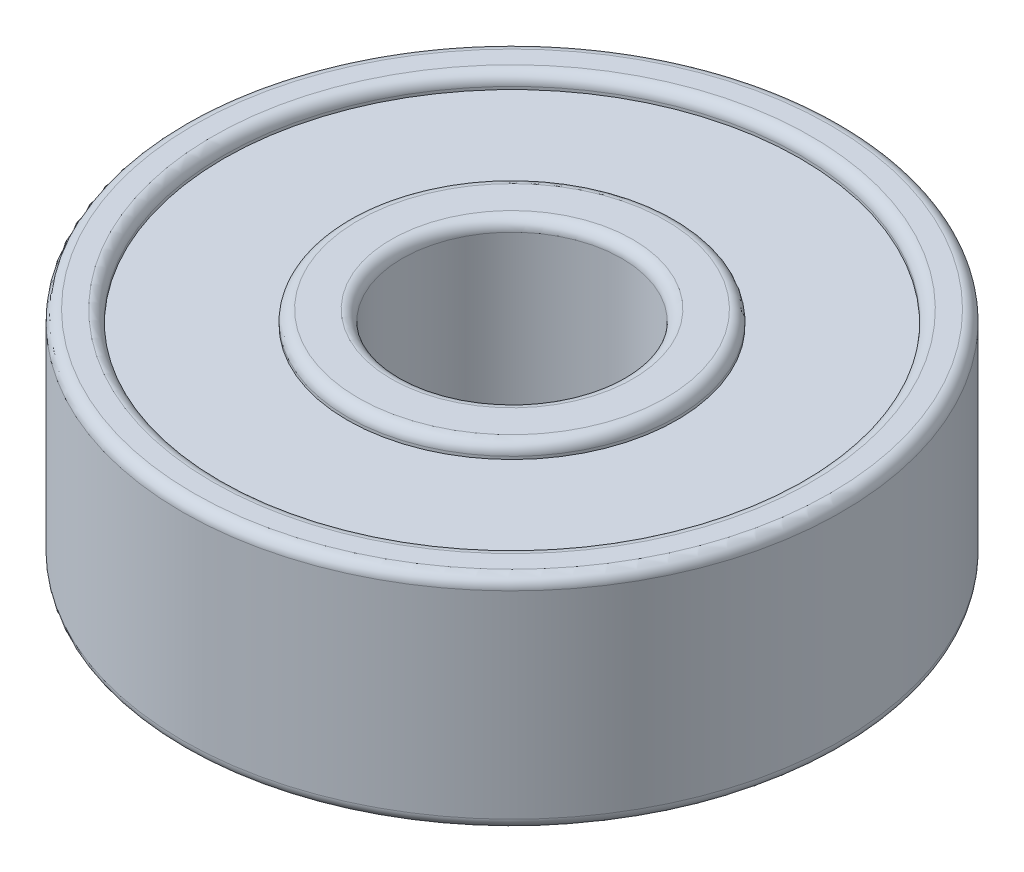
from build123d import *

# Parameters (mm, degrees)
SKETCH1_R           = 6
SKETCH1_R_2         = 2
BOSS_EXTRUDE1_DEPTH = 4
SKETCH2_R           = 5.25
SKETCH2_R_2         = 3
CUT_EXTRUDE1_DEPTH  = 0.25
SKETCH3_R           = 5.25
SKETCH3_R_2         = 3
CUT_EXTRUDE2_DEPTH  = 0.25
FILLET1_R           = 0.2


with BuildPart() as part:
    # Sketch1 → Boss-Extrude1 (new body)
    with BuildSketch(Plane(origin=(0, 0, 0), x_dir=(1, 0, 0), z_dir=(0, 1, 0))):
        Circle(SKETCH1_R)
        Circle(SKETCH1_R_2, mode=Mode.SUBTRACT)
    extrude(amount=BOSS_EXTRUDE1_DEPTH)

    # Sketch2 → Cut-Extrude1 (cut)
    with BuildSketch(Plane(origin=(0, 4, 0), x_dir=(1, 0, 0), z_dir=(0, 1, 0))):
        Circle(SKETCH2_R)
        Circle(SKETCH2_R_2, mode=Mode.SUBTRACT)
    extrude(amount=-CUT_EXTRUDE1_DEPTH, mode=Mode.SUBTRACT)

    # Sketch3 → Cut-Extrude2 (cut)
    with BuildSketch(Plane.XZ):
        Circle(SKETCH3_R)
        Circle(SKETCH3_R_2, mode=Mode.SUBTRACT)
    extrude(amount=-CUT_EXTRUDE2_DEPTH, mode=Mode.SUBTRACT)

    # Fillet1
    fillet1_edges = [part.edges().sort_by_distance(p)[0] for p in [
        (-5.25, 4, 0),
        (-3, 4, 0),
        (-5.25, 0, 0),
        (-6, 0, 0),
        (-3, 0, 0),
        (-6, 4, 0),
        (-2, 0, 0),
        (-2, 4, 0),
    ]]
    fillet(fillet1_edges, radius=FILLET1_R)


solid = part.part
